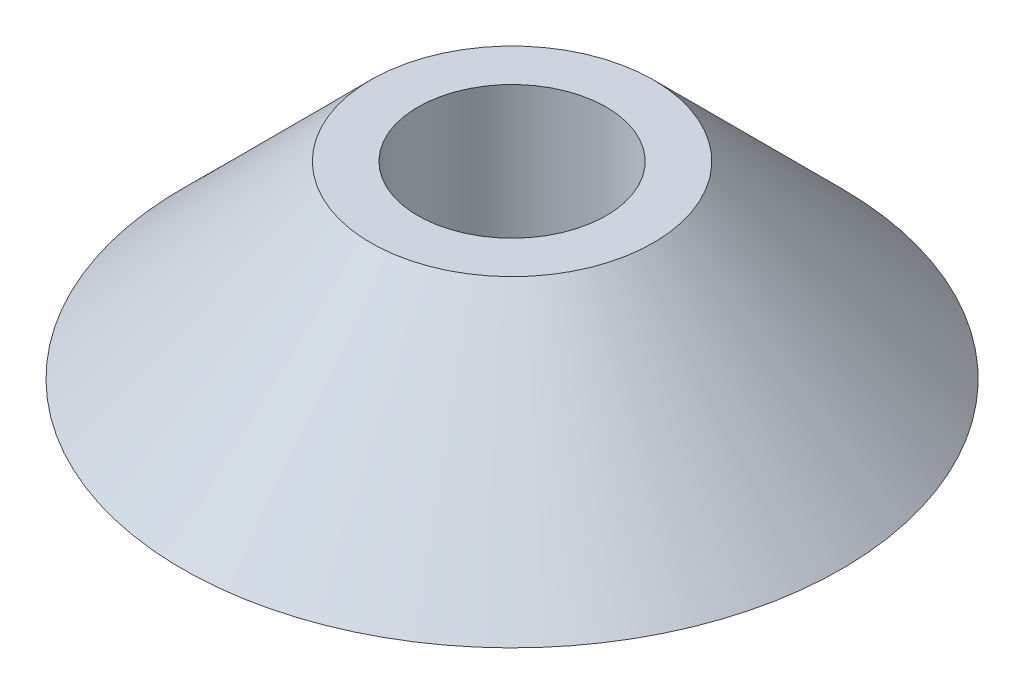
from build123d import *


with BuildPart() as part:
    # Sketch1 → Revolve1 (revolve)
    with BuildSketch(Plane.XY):
        Polygon((6.35, 0), (22.225, 0), (9.525, 12.7), (6.35, 12.7), align=None)
    revolve(axis=Axis((0, -1000.69375591, 0), (0, 1, 0)))


solid = part.part
